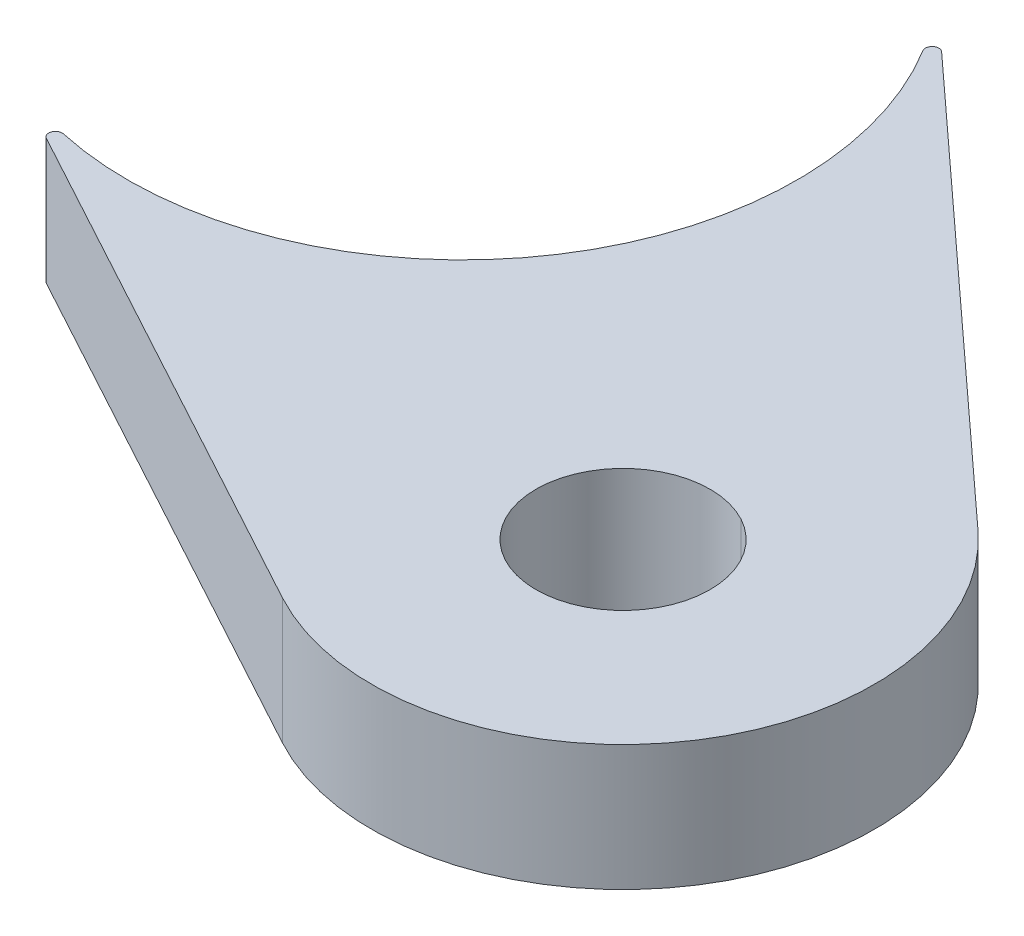
from build123d import *

# Parameters (mm, degrees)
SKETCH1_R           = 3.3
BOSS_EXTRUDE1_DEPTH = 4.7625
FILLET1_R           = 0.254


with BuildPart() as part:
    # Sketch1 → Boss-Extrude1 (new body)
    with BuildSketch(Plane(origin=(0, 0, 0), x_dir=(1, 0, 0), z_dir=(0, 1, 0))):
        with BuildLine():
            Line((16.658671, -23.484448), (-6.055469, -11.163391))
            ThreePointArc((-6.055469, -11.163391), (10.341596, -7.371661), (8.57781, 9.365425))
            Line((8.57781, 9.365425), (27.63363, -8.087836))
            ThreePointArc((27.63363, -8.087836), (28.95647, -20.64065), (16.658671, -23.484448))
        make_face()
        with Locations((21.200273, -15.111905)):
            Circle(SKETCH1_R, mode=Mode.SUBTRACT)
    extrude(amount=BOSS_EXTRUDE1_DEPTH)

    # Fillet1
    fillet1_edges = [part.edges().sort_by_distance(p)[0] for p in [
        (-6.055469, 2.38125, 11.163391),
        (8.57781, 2.38125, -9.365425),
    ]]
    fillet(fillet1_edges, radius=FILLET1_R)


solid = part.part
